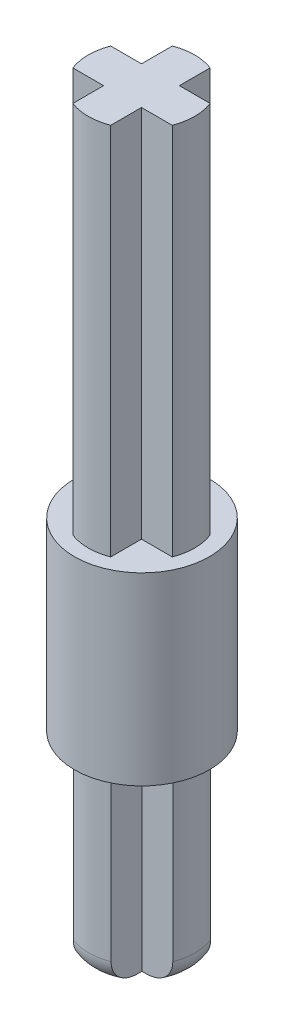
from build123d import *

# Parameters (mm, degrees)
BOSS_EXTRUDE1_DEPTH = 15.8
FILLET1_R           = 1
FILLET2_R           = 1
FILLET3_R           = 1
FILLET4_R           = 1
SKETCH3_R           = 2.85
BOSS_EXTRUDE2_DEPTH = 7.8
BOSS_EXTRUDE4_DEPTH = 15.8


with BuildPart() as part:
    # Sketch1 → Boss-Extrude1 (new body)
    with BuildSketch(Plane(origin=(0, 0, 0), x_dir=(1, 0, 0), z_dir=(0, 1, 0))):
        with BuildLine():
            Line((-0.8, -0.8), (-0.8, -2.102974084))
            ThreePointArc((-0.8, -2.102974084), (0, -2.25), (0.8, -2.102974084))
            Line((0.8, -2.102974084), (0.8, -0.8))
            Line((0.8, -0.8), (2.102974084, -0.8))
            ThreePointArc((2.102974084, -0.8), (2.25, 0), (2.102974084, 0.8))
            Line((2.102974084, 0.8), (0.8, 0.8))
            Line((0.8, 0.8), (0.8, 2.102974084))
            ThreePointArc((0.8, 2.102974084), (0, 2.25), (-0.8, 2.102974084))
            Line((-0.8, 2.102974084), (-0.8, 0.8))
            Line((-0.8, 0.8), (-2.102974084, 0.8))
            ThreePointArc((-2.102974084, 0.8), (-2.25, 0), (-2.102974084, -0.8))
            Line((-2.102974084, -0.8), (-0.8, -0.8))
        make_face()
    extrude(amount=BOSS_EXTRUDE1_DEPTH)

    # Fillet1
    fillet1_edges = [part.edges().sort_by_distance(p)[0] for p in [
        (-2.25, 0, 0),
    ]]
    fillet(fillet1_edges, radius=FILLET1_R)

    # Fillet2
    fillet2_edges = [part.edges().sort_by_distance(p)[0] for p in [
        (0, 0, 2.25),
    ]]
    fillet(fillet2_edges, radius=FILLET2_R)

    # Fillet3
    fillet3_edges = [part.edges().sort_by_distance(p)[0] for p in [
        (2.25, 0, 0),
    ]]
    fillet(fillet3_edges, radius=FILLET3_R)

    # Fillet4
    fillet4_edges = [part.edges().sort_by_distance(p)[0] for p in [
        (0, 0, -2.25),
    ]]
    fillet(fillet4_edges, radius=FILLET4_R)

    # Sketch3 → Boss-Extrude2 (add)
    with BuildSketch(Plane(origin=(0, 15.8, 0), x_dir=(1, 0, 0), z_dir=(0, 1, 0))):
        with Locations(Location((0, 0, 0), (0, 0, 270))):
            Circle(SKETCH3_R)
    extrude(amount=-BOSS_EXTRUDE2_DEPTH)

    # Sketch6 → Boss-Extrude4 (add)
    with BuildSketch(Plane(origin=(0, 15.8, 0), x_dir=(1, 0, 0), z_dir=(0, 1, 0))):
        with BuildLine():
            Line((-0.82856076, -0.791213071), (-0.82856076, -2.094187155))
            ThreePointArc((-0.82856076, -2.094187155), (-0.02856076, -2.241213071), (0.77143924, -2.094187155))
            Line((0.77143924, -2.094187155), (0.77143924, -0.791213071))
            Line((0.77143924, -0.791213071), (2.074413324, -0.791213071))
            ThreePointArc((2.074413324, -0.791213071), (2.22143924, 0.008786929), (2.074413324, 0.808786929))
            Line((2.074413324, 0.808786929), (0.77143924, 0.808786929))
            Line((0.77143924, 0.808786929), (0.77143924, 2.111761014))
            ThreePointArc((0.77143924, 2.111761014), (-0.02856076, 2.258786929), (-0.82856076, 2.111761014))
            Line((-0.82856076, 2.111761014), (-0.82856076, 0.808786929))
            Line((-0.82856076, 0.808786929), (-2.131534845, 0.808786929))
            ThreePointArc((-2.131534845, 0.808786929), (-2.27856076, 0.008786929), (-2.131534845, -0.791213071))
            Line((-2.131534845, -0.791213071), (-0.82856076, -0.791213071))
        make_face()
    extrude(amount=BOSS_EXTRUDE4_DEPTH)


solid = part.part
